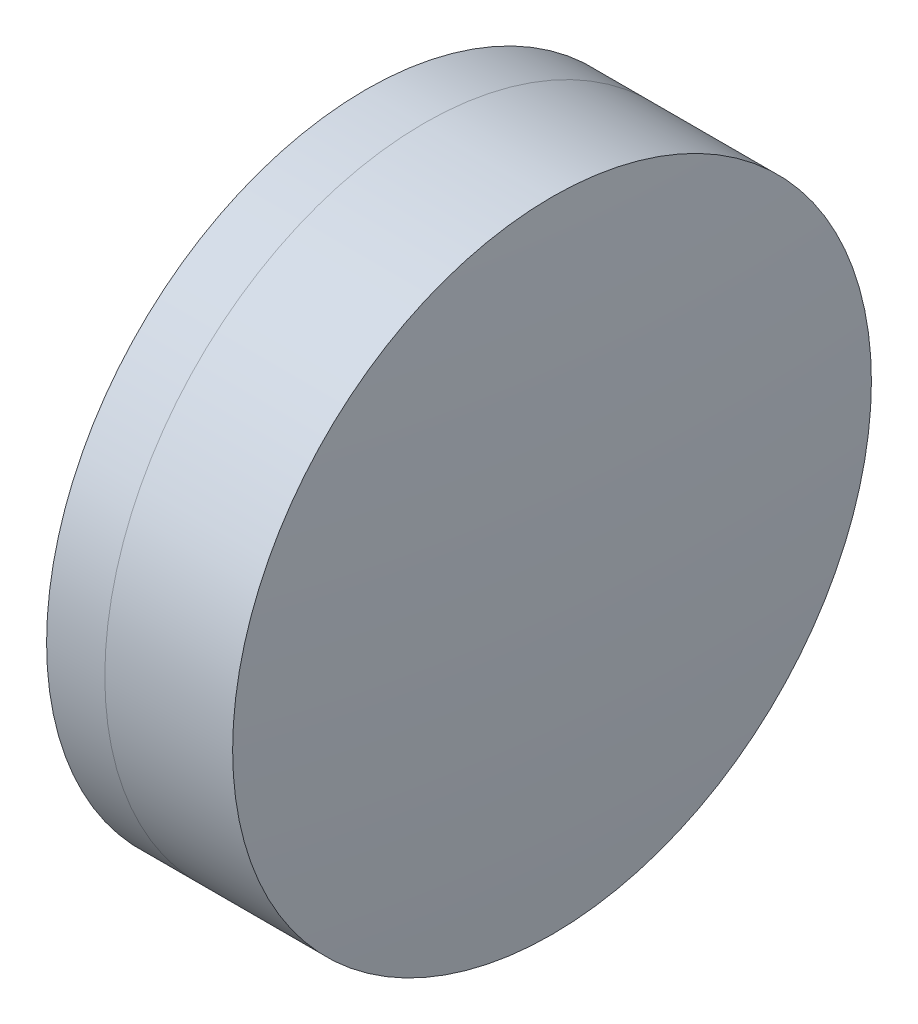
from build123d import *


with BuildPart() as part:
    # 草图1 one side → 旋转1 (revolve)
    with BuildSketch(Plane(origin=(0, 0, 0), x_dir=(1, 0, 0), z_dir=(0, 1, 0)), mode=Mode.PRIVATE) as revolve_1_sk:
        with BuildLine():
            ThreePointArc((274.454823773, 6.35), (273.672172998, 3.21777633), (273.40895665, 0))
            Line((273.40895665, 0), (276.90895665, 0))
            ThreePointArc((276.90895665, 0), (276.581549894, 3.24049128), (275.612563596, 6.35))
            Line((275.612563596, 6.35), (274.454823773, 6.35))
        make_face()
    revolve(revolve_1_sk.sketch.rotate(Axis((124.523309526, 0, 0), (1, 0, 0)), 180), axis=Axis((124.523309526, 0, 0), (1, 0, 0)))  # turned: the seam where the file's is


with BuildPart() as body_2:
    # 草图2 one side → 旋转3 (revolve)
    with BuildSketch(Plane(origin=(0, 0, 0), x_dir=(1, 0, 0), z_dir=(0, 1, 0)), mode=Mode.PRIVATE) as revolve_3_sk:
        with BuildLine():
            Line((278.153661609, 6.35), (275.612563596, 6.35))
            ThreePointArc((275.612563596, 6.35), (276.581549894, 3.24049128), (276.90895665, 0))
            Line((276.90895665, 0), (278.40895665, 0))
            ThreePointArc((278.40895665, 0), (278.34510712, 3.177564931), (278.153661609, 6.35))
        make_face()
    revolve(revolve_3_sk.sketch.rotate(Axis((-0.551919993, 0, 0), (1, 0, 0)), 180), axis=Axis((-0.551919993, 0, 0), (1, 0, 0)))  # turned: the seam where the file's is


solid = Compound([part.part, body_2.part])
